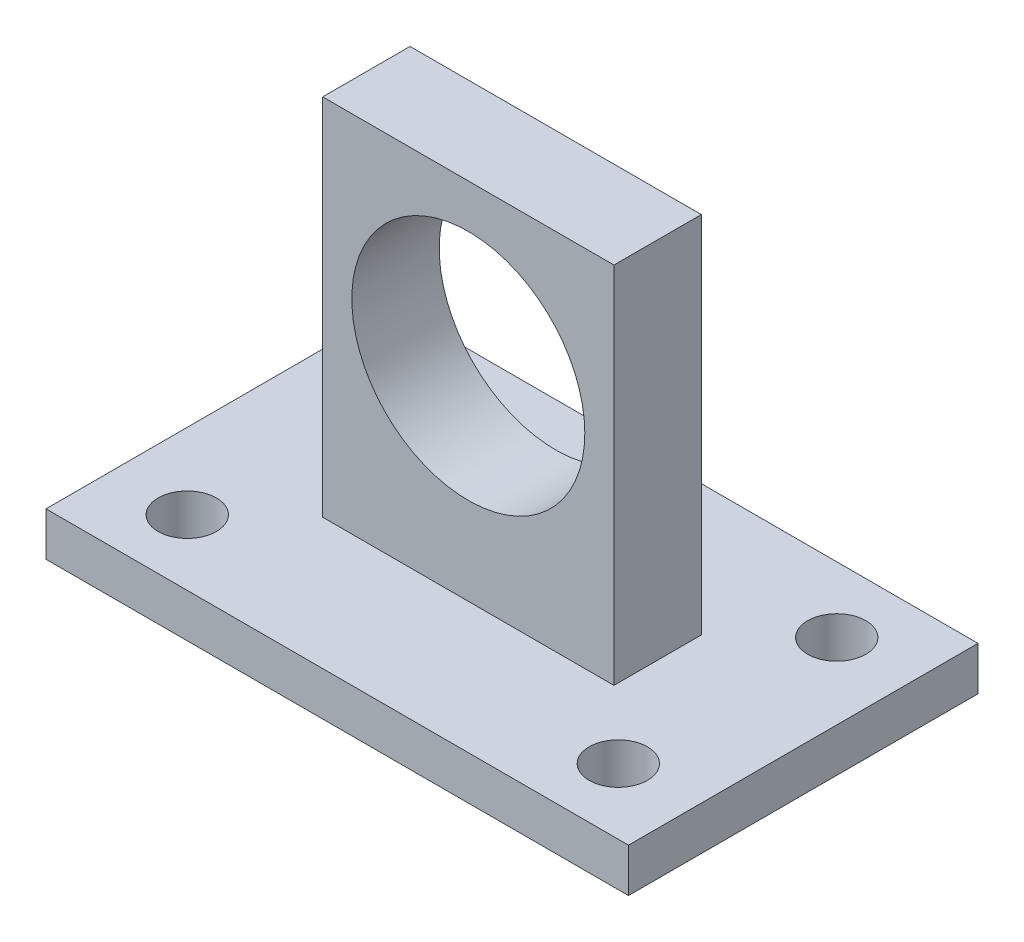
from build123d import *

# Parameters (mm, degrees)
SKETCH_1_W          = 40
SKETCH_1_H          = 24
SKETCH_1_R          = 2
EXTRUDE_1_DEPTH     = 3
SKETCH_2_W          = 20
SKETCH_2_H          = 6
EXTRUDE_2_DEPTH     = 25
SKETCH_3_R          = 8
CUT_EXTRUDE_1_DEPTH = 10


with BuildPart() as part:
    # 草图1 → 凸台-拉伸1 (new body)
    with BuildSketch(Plane(origin=(0, 0, 0), x_dir=(1, 0, 0), z_dir=(0, 1, 0))):
        Rectangle(SKETCH_1_W, SKETCH_1_H)
        with Locations((-14.8, -7.5)):
            Circle(SKETCH_1_R, mode=Mode.SUBTRACT)
        with Locations((14.8, -7.5)):
            Circle(SKETCH_1_R, mode=Mode.SUBTRACT)
        with Locations((-14.8, 7.5)):
            Circle(SKETCH_1_R, mode=Mode.SUBTRACT)
        with Locations((14.8, 7.5)):
            Circle(SKETCH_1_R, mode=Mode.SUBTRACT)
    extrude(amount=EXTRUDE_1_DEPTH)

    # 草图2 → 凸台-拉伸2 (add)
    with BuildSketch(Plane(origin=(0, 3, 0), x_dir=(1, 0, 0), z_dir=(0, 1, 0))):
        Rectangle(SKETCH_2_W, SKETCH_2_H)
    extrude(amount=EXTRUDE_2_DEPTH)

    # 草图3 → 切除-拉伸1 (cut)
    with BuildSketch(Plane.XY.offset(3)):
        with Locations((0, 17)):
            Circle(SKETCH_3_R)
    extrude(amount=-CUT_EXTRUDE_1_DEPTH, mode=Mode.SUBTRACT)


solid = part.part
